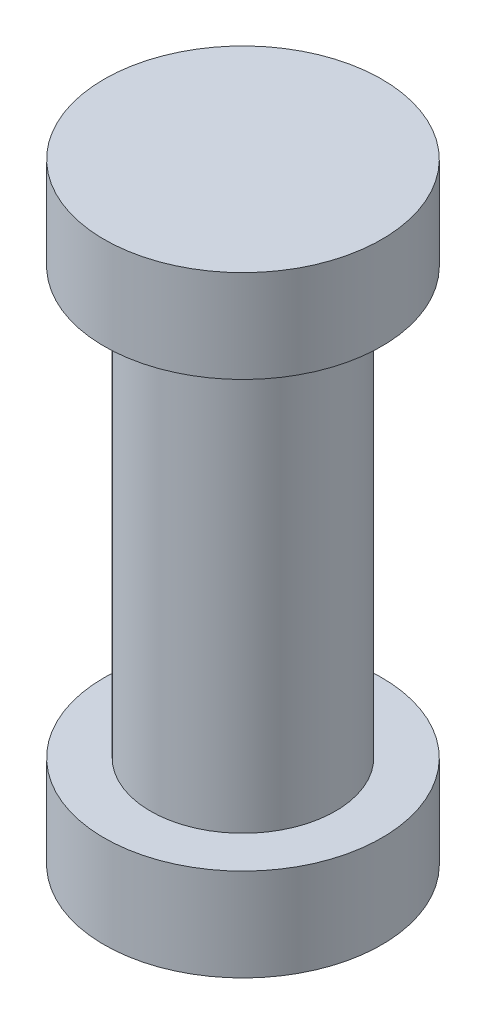
from build123d import *


with BuildPart() as part:
    # Sketch1 → Revolve1 (revolve)
    with BuildSketch(Plane.XY):
        Polygon((0, 0), (9.525, 0), (9.525, 6.35), (6.346825, 6.35), (6.346825, 35.56), (9.525, 35.56), (9.525, 41.91), (0, 41.91), align=None)
    revolve(axis=Axis((0, 41.91, 0), (0, -1, 0)))


solid = part.part
